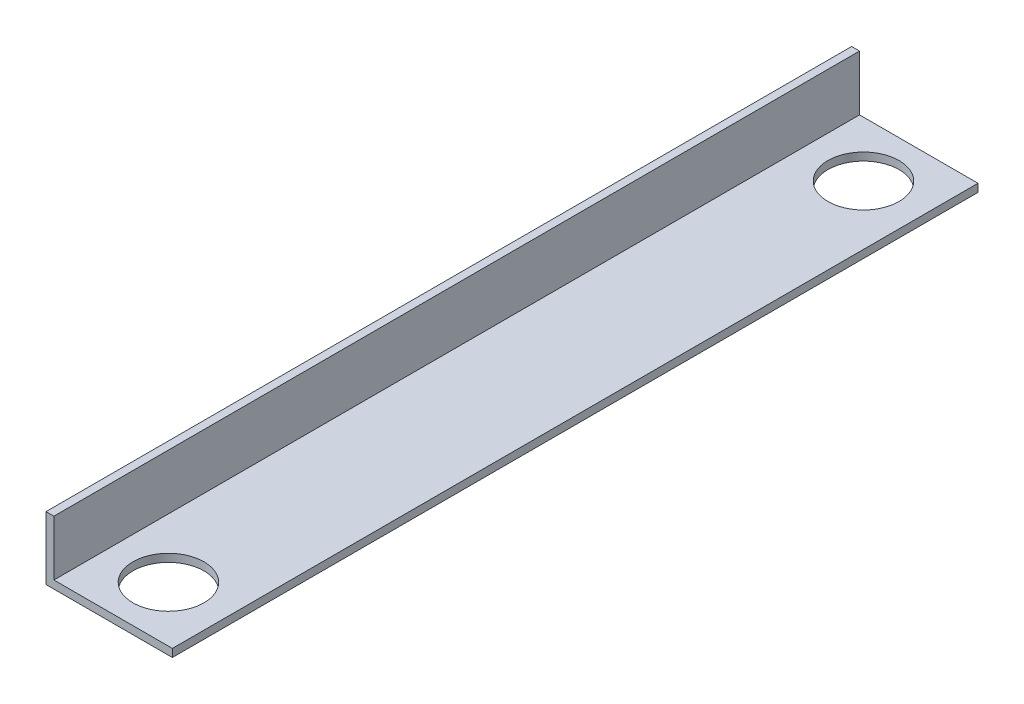
from build123d import *

# Parameters (mm, degrees)
BOSS_EXTRUDE1_DEPTH = 323.85
SKETCH2_R           = 14.2875
CUT_EXTRUDE1_DEPTH  = 4.175


with BuildPart() as part:
    # Sketch1 → Boss-Extrude1 (new body)
    with BuildSketch(Plane.XY):
        Polygon((0, 0), (50.8, 0), (50.8, 3.175), (3.175, 3.175), (3.175, 25.4), (0, 25.4), align=None)
    extrude(amount=BOSS_EXTRUDE1_DEPTH)

    # Sketch2 → Cut-Extrude1 (cut, through all)
    with BuildSketch(Plane(origin=(0, 3.175, 0), x_dir=(1, 0, 0), z_dir=(0, 1, 0))):
        with Locations((26.9875, -301.625)):
            Circle(SKETCH2_R)
        with Locations((26.9875, -22.225)):
            Circle(SKETCH2_R)
    extrude(amount=-CUT_EXTRUDE1_DEPTH, mode=Mode.SUBTRACT)


solid = part.part
